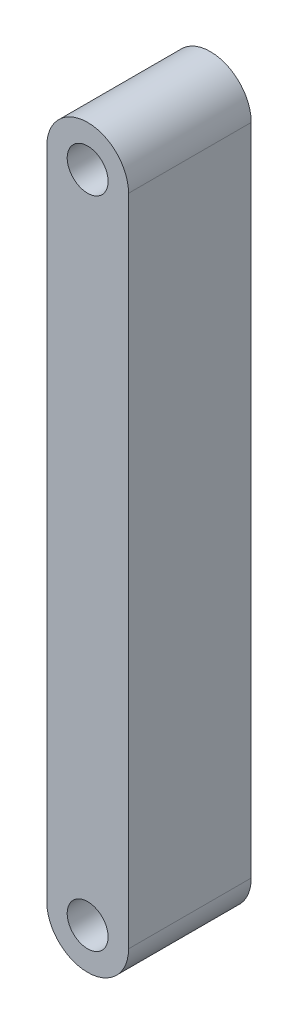
from build123d import *

# Parameters (mm, degrees)
BOSS_EXTRUDE1_DEPTH = 15
SKETCH2_R           = 2.5
CUT_EXTRUDE1_DEPTH  = 15


with BuildPart() as part:
    # Sketch1 → Boss-Extrude1 (new body)
    with BuildSketch(Plane.XY):
        with BuildLine():
            ThreePointArc((5, 40), (0, 35), (-5, 40))
            Line((-5, 40), (-5, -40))
            ThreePointArc((-5, -40), (0, -35), (5, -40))
            Line((5, -40), (5, 40))
        make_face()
        with BuildLine():
            ThreePointArc((5, 40), (0, 45), (-5, 40))
            Line((-5, 40), (5, 40))
        make_face()
        with BuildLine():
            Line((5, 40), (-5, 40))
            ThreePointArc((-5, 40), (0, 35), (5, 40))
        make_face()
        with BuildLine():
            ThreePointArc((5, -40), (0, -35), (-5, -40))
            Line((-5, -40), (5, -40))
        make_face()
        with BuildLine():
            Line((5, -40), (-5, -40))
            ThreePointArc((-5, -40), (0, -45), (5, -40))
        make_face()
    extrude(amount=BOSS_EXTRUDE1_DEPTH)

    # Sketch2 → Cut-Extrude1 (cut)
    with BuildSketch(Plane.XY.offset(15)):
        with Locations((0, 40)):
            Circle(SKETCH2_R)
        with Locations((0, -40)):
            Circle(SKETCH2_R)
    extrude(amount=-CUT_EXTRUDE1_DEPTH, mode=Mode.SUBTRACT)


solid = part.part
